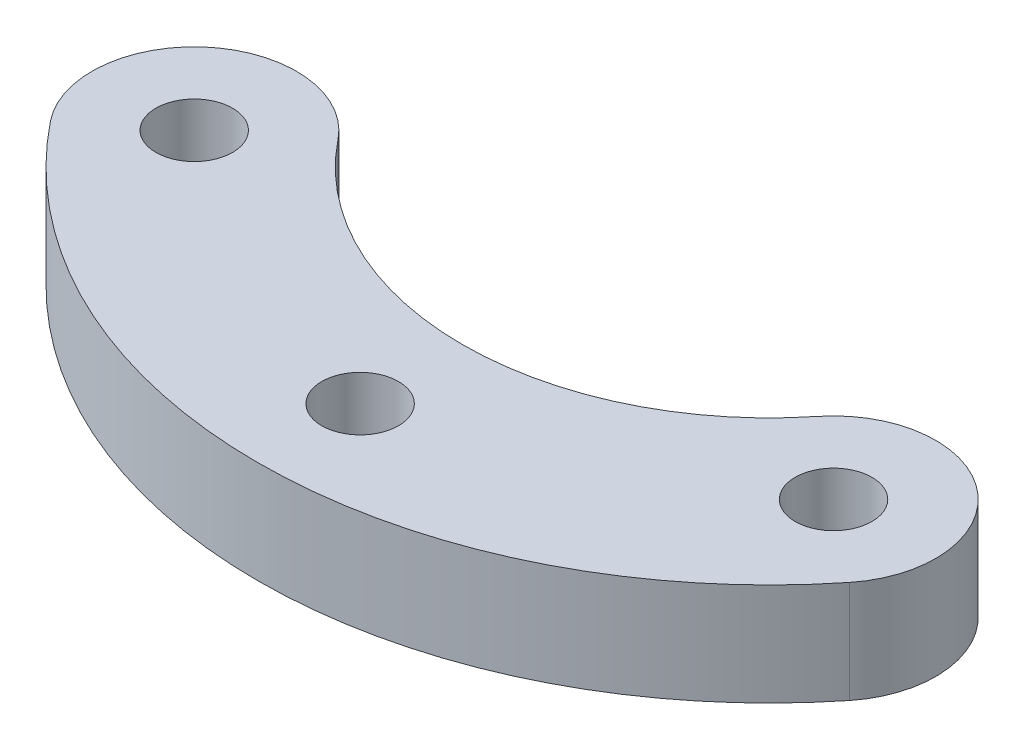
from build123d import *

# Parameters (mm, degrees)
SKETCH1_R           = 1.5
BOSS_EXTRUDE1_DEPTH = 4


with BuildPart() as part:
    # Sketch1 → Boss-Extrude1 (new body)
    with BuildSketch(Plane(origin=(0, 0, 0), x_dir=(1, 0, 0), z_dir=(0, 1, 0))):
        with BuildLine():
            ThreePointArc((-9.375, -7.490619133), (0, -12), (9.375, -7.490619133))
            ThreePointArc((9.375, -7.490619133), (14.996873044, -6.862492178), (15.625, -12.484365222))
            ThreePointArc((15.625, -12.484365222), (0, -20), (-15.625, -12.484365222))
            ThreePointArc((-15.625, -12.484365222), (-14.996873044, -6.862492178), (-9.375, -7.490619133))
        make_face()
        with Locations((-12.5, -9.987492178)):
            Circle(SKETCH1_R, mode=Mode.SUBTRACT)
        with Locations((12.5, -9.987492178)):
            Circle(SKETCH1_R, mode=Mode.SUBTRACT)
        with Locations((0, -16)):
            Circle(SKETCH1_R, mode=Mode.SUBTRACT)
    extrude(amount=BOSS_EXTRUDE1_DEPTH)


solid = part.part
